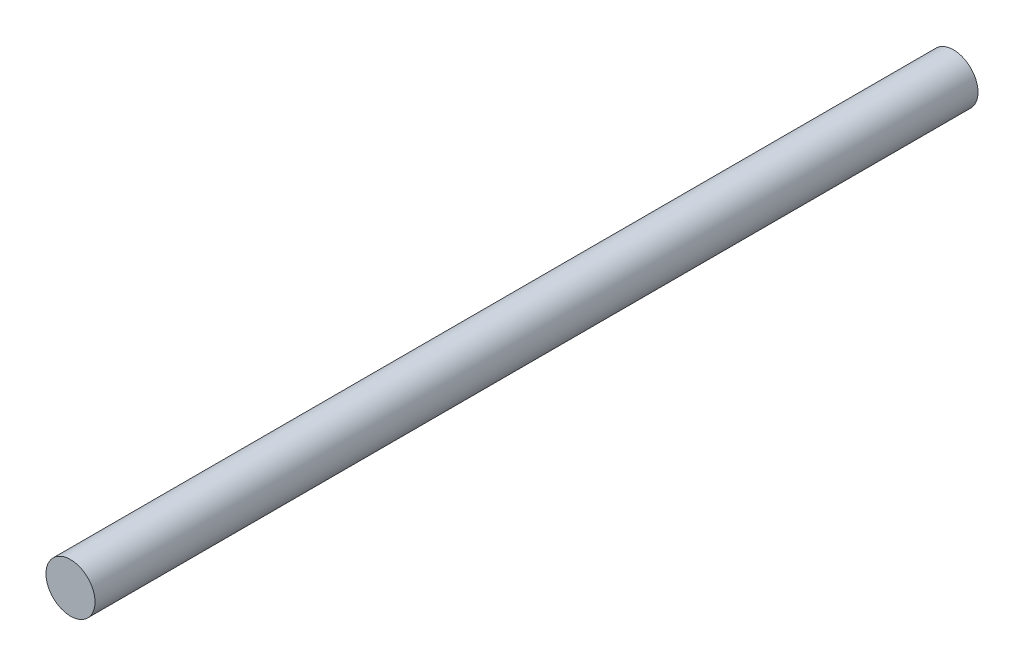
from build123d import *

# Parameters (mm, degrees)
SKETCH1_R           = 10
BOSS_EXTRUDE1_DEPTH = 180


with BuildPart() as part:
    # Sketch1 → Boss-Extrude1 (new body, symmetric)
    with BuildSketch(Plane.XY):
        Circle(SKETCH1_R)
    extrude(amount=BOSS_EXTRUDE1_DEPTH, both=True)


solid = part.part
